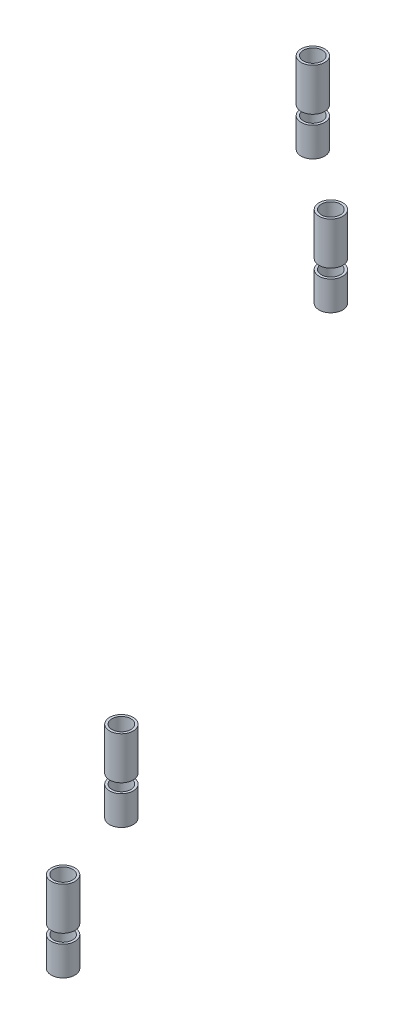
from build123d import *

# Parameters (mm, degrees)
SZKIC1_R                      = 2.5
SZKIC1_R_2                    = 2
DODANIE_WYCI_GNI_CIE1_DEPTH   = 9
DODANIE_WYCI_GNI_CIE1_2_DEPTH = 9
DODANIE_WYCI_GNI_CIE1_3_DEPTH = 9
DODANIE_WYCI_GNI_CIE1_4_DEPTH = 9
SZKIC2_R                      = 2.5
SZKIC2_R_2                    = 2.000000003
DODANIE_WYCI_GNI_CIE2_DEPTH   = 6.2
SZKIC2_R_3                    = 1.999999997
DODANIE_WYCI_GNI_CIE2_2_DEPTH = 6.2
SZKIC2_R_4                    = 2
DODANIE_WYCI_GNI_CIE2_3_DEPTH = 6.2
DODANIE_WYCI_GNI_CIE2_4_DEPTH = 6.2


with BuildPart() as part:
    # Szkic1 → Dodanie-wyciągnięcie1 (new body)
    with BuildSketch(Plane.XZ.offset(-472.5)):
        with Locations((-209.294177747, 235.232823684)):
            Circle(SZKIC1_R)
        with Locations((-209.294177747, 235.232823684)):
            Circle(SZKIC1_R_2, mode=Mode.SUBTRACT)
    extrude(amount=DODANIE_WYCI_GNI_CIE1_DEPTH)


with BuildPart() as body_2:
    # Szkic1 → Dodanie-wyci_gni_cie1 2 (new body)
    with BuildSketch(Plane.XZ.offset(-472.5)):
        with Locations((-179.166238959, 261.544556892)):
            Circle(SZKIC1_R)
        with Locations((-179.166238959, 261.544556892)):
            Circle(SZKIC1_R_2, mode=Mode.SUBTRACT)
    extrude(amount=DODANIE_WYCI_GNI_CIE1_2_DEPTH)


with BuildPart() as body_3:
    # Szkic1 → Dodanie-wyci_gni_cie1 3 (new body)
    with BuildSketch(Plane.XZ.offset(-472.5)):
        with Locations((-106.941386538, 378.144106321)):
            Circle(SZKIC1_R)
        with Locations((-106.941386538, 378.144106321)):
            Circle(SZKIC1_R_2, mode=Mode.SUBTRACT)
    extrude(amount=DODANIE_WYCI_GNI_CIE1_3_DEPTH)


with BuildPart() as body_4:
    # Szkic1 → Dodanie-wyci_gni_cie1 4 (new body)
    with BuildSketch(Plane.XZ.offset(-472.5)):
        with Locations((-85.513533731, 411.920534849)):
            Circle(SZKIC1_R)
        with Locations((-85.513533731, 411.920534849)):
            Circle(SZKIC1_R_2, mode=Mode.SUBTRACT)
    extrude(amount=DODANIE_WYCI_GNI_CIE1_4_DEPTH)


with BuildPart() as body_5:
    # Szkic2 → Dodanie-wyciągnięcie2 (new body)
    with BuildSketch(Plane.XZ.offset(-461.5)):
        with Locations((-209.294177747, 235.232823684)):
            Circle(SZKIC2_R)
        with Locations((-209.294177747, 235.232823684)):
            Circle(SZKIC2_R_2, mode=Mode.SUBTRACT)
    extrude(amount=DODANIE_WYCI_GNI_CIE2_DEPTH)


with BuildPart() as body_6:
    # Szkic2 → Dodanie-wyci_gni_cie2 2 (new body)
    with BuildSketch(Plane.XZ.offset(-461.5)):
        with Locations((-179.166238959, 261.544556892)):
            Circle(SZKIC2_R)
        with Locations((-179.166238959, 261.544556892)):
            Circle(SZKIC2_R_3, mode=Mode.SUBTRACT)
    extrude(amount=DODANIE_WYCI_GNI_CIE2_2_DEPTH)


with BuildPart() as body_7:
    # Szkic2 → Dodanie-wyci_gni_cie2 3 (new body)
    with BuildSketch(Plane.XZ.offset(-461.5)):
        with Locations((-106.941386538, 378.144106321)):
            Circle(SZKIC2_R)
        with Locations((-106.941386538, 378.144106321)):
            Circle(SZKIC2_R_4, mode=Mode.SUBTRACT)
    extrude(amount=DODANIE_WYCI_GNI_CIE2_3_DEPTH)


with BuildPart() as body_8:
    # Szkic2 → Dodanie-wyci_gni_cie2 4 (new body)
    with BuildSketch(Plane.XZ.offset(-461.5)):
        with Locations((-85.513533731, 411.920534849)):
            Circle(SZKIC2_R)
        with Locations((-85.513533731, 411.920534849)):
            Circle(SZKIC2_R_4, mode=Mode.SUBTRACT)
    extrude(amount=DODANIE_WYCI_GNI_CIE2_4_DEPTH)


solid = Compound([part.part, body_2.part, body_3.part, body_4.part, body_5.part, body_6.part, body_7.part, body_8.part])
